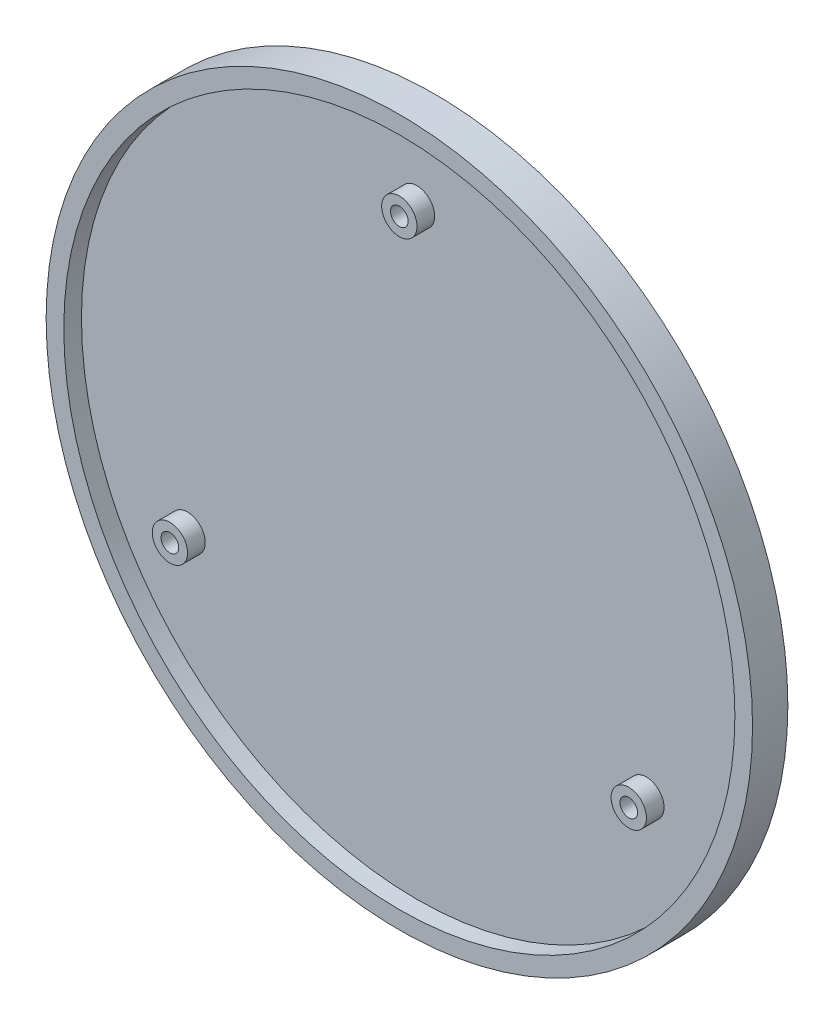
from build123d import *

# Parameters (mm, degrees)
SKETCH_1_R          = 40
EXTRUDE_1_DEPTH     = 4
SHELL_1_T           = -2
SKETCH_2_R          = 2
SKETCH_2_R_2        = 1
EXTRUDE_2_DEPTH     = 2
SKETCH_3_R          = 1
CUT_EXTRUDE_1_DEPTH = 20
SKETCH_4_R          = 1.6
CUT_EXTRUDE_2_DEPTH = 1.2


with BuildPart() as part:
    # 草图1 → 凸台-拉伸1 (new body)
    with BuildSketch(Plane.XY):
        Circle(SKETCH_1_R)
    extrude(amount=EXTRUDE_1_DEPTH)

    # 抽壳1
    shell_1_openings = [part.faces().sort_by_distance(p)[0] for p in [
        (0, 0, 4),
    ]]
    offset(amount=SHELL_1_T, openings=shell_1_openings, kind=Kind.INTERSECTION)

    # 草图2 → 凸台-拉伸2 (add)
    with BuildSketch(Plane.XY.offset(2)):
        with Locations((0, 30)):
            Circle(SKETCH_2_R)
        with Locations((0, 30)):
            Circle(SKETCH_2_R_2, mode=Mode.SUBTRACT)
        with Locations((25.980762114, -15)):
            Circle(SKETCH_2_R)
        with Locations((25.980762114, -15)):
            Circle(SKETCH_2_R_2, mode=Mode.SUBTRACT)
        with Locations((-25.980762114, -15)):
            Circle(SKETCH_2_R)
        with Locations((-25.980762114, -15)):
            Circle(SKETCH_2_R_2, mode=Mode.SUBTRACT)
    extrude(amount=EXTRUDE_2_DEPTH)

    # 草图3 → 切除-拉伸1 (cut)
    with BuildSketch(Plane.XY.offset(4)):
        with Locations((25.980762114, -15)):
            Circle(SKETCH_3_R)
        with Locations((-25.980762114, -15)):
            Circle(SKETCH_3_R)
        with Locations((0, 30)):
            Circle(SKETCH_3_R)
    extrude(amount=-CUT_EXTRUDE_1_DEPTH, mode=Mode.SUBTRACT)

    # 草图4 → 切除-拉伸2 (cut)
    with BuildSketch(Plane(origin=(0, 0, 0), x_dir=(-1, 0, 0), z_dir=(0, 0, -1))):
        with Locations((-25.980762114, -15)):
            Circle(SKETCH_4_R)
        with Locations((0, 30)):
            Circle(SKETCH_4_R)
        with Locations((25.980762114, -15)):
            Circle(SKETCH_4_R)
    extrude(amount=-CUT_EXTRUDE_2_DEPTH, mode=Mode.SUBTRACT)


solid = part.part
